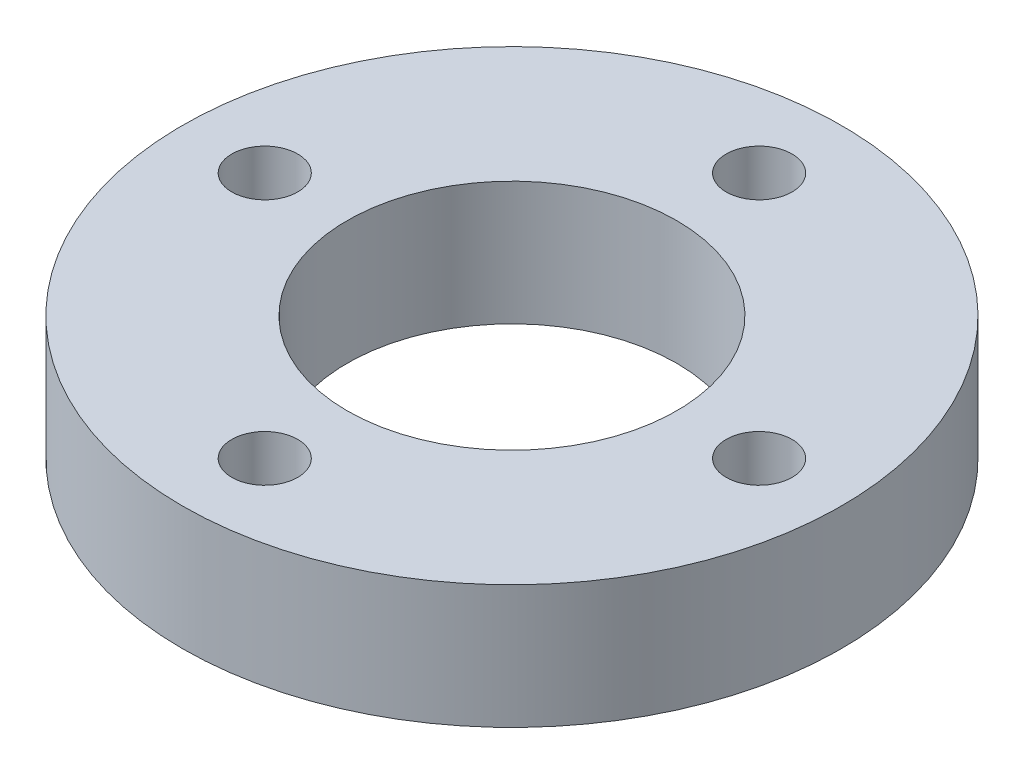
from build123d import *

# Parameters (mm, degrees)
SKETCH_1_R      = 16
SKETCH_1_R_2    = 8
SKETCH_1_R_3    = 1.6
EXTRUDE_1_DEPTH = 6


with BuildPart() as part:
    # 草图1 → 凸台-拉伸1 (new body)
    with BuildSketch(Plane(origin=(0, 0, 0), x_dir=(1, 0, 0), z_dir=(0, 1, 0))):
        Circle(SKETCH_1_R)
        Circle(SKETCH_1_R_2, mode=Mode.SUBTRACT)
        with Locations((-12, 0)):
            Circle(SKETCH_1_R_3, mode=Mode.SUBTRACT)
        with Locations((0, 12)):
            Circle(SKETCH_1_R_3, mode=Mode.SUBTRACT)
        with Locations((12, 0)):
            Circle(SKETCH_1_R_3, mode=Mode.SUBTRACT)
        with Locations((0, -12)):
            Circle(SKETCH_1_R_3, mode=Mode.SUBTRACT)
    extrude(amount=EXTRUDE_1_DEPTH)


solid = part.part
